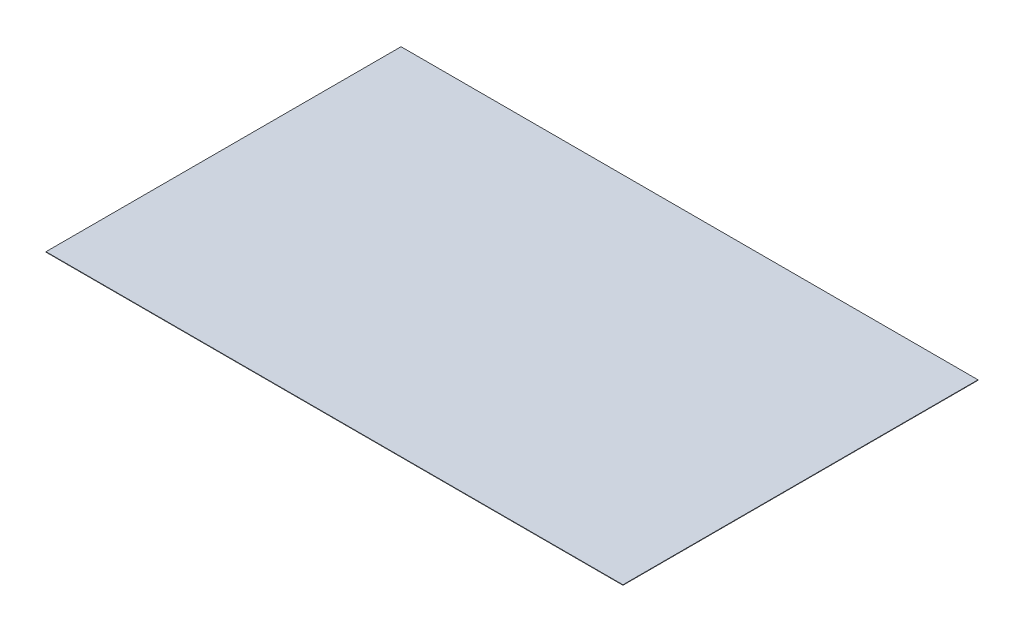
from build123d import *

# Parameters (mm, degrees)
SKETCH1_W           = 13000
SKETCH1_H           = 8000
BOSS_EXTRUDE1_DEPTH = 10


with BuildPart() as part:
    # Sketch1 → Boss-Extrude1 (new body)
    with BuildSketch(Plane(origin=(0, 0, 0), x_dir=(1, 0, 0), z_dir=(0, 1, 0))):
        Rectangle(SKETCH1_W, SKETCH1_H)
    extrude(amount=BOSS_EXTRUDE1_DEPTH)


solid = part.part
